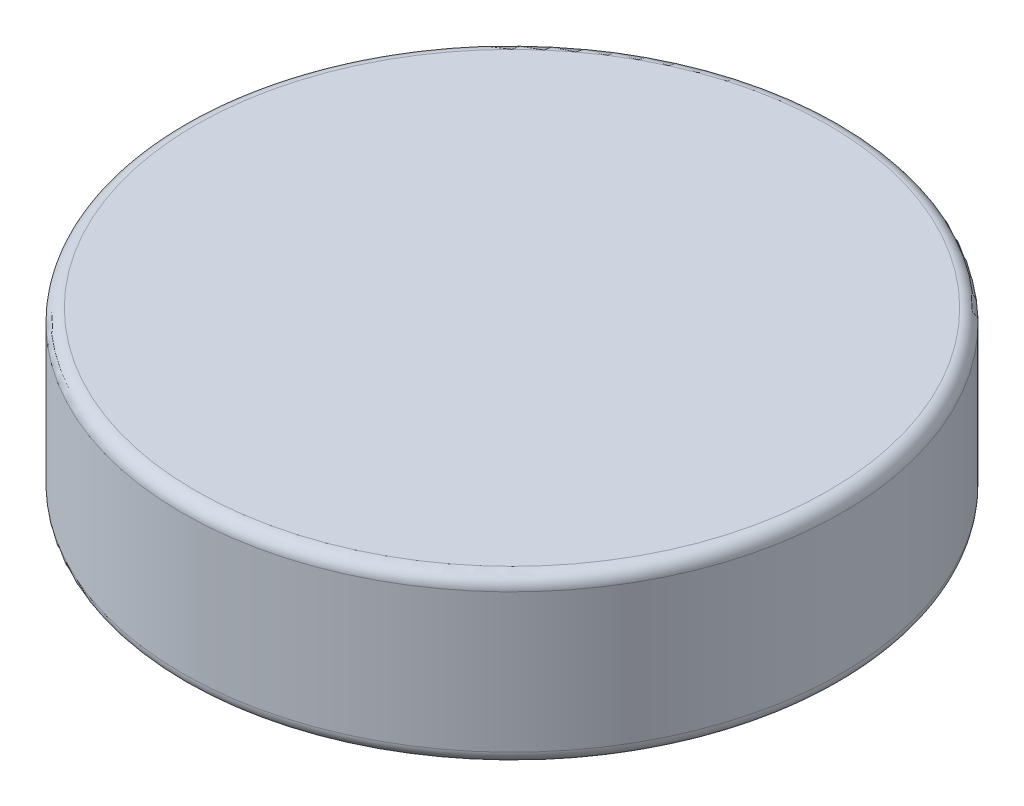
from build123d import *

# Parameters (mm, degrees)
SKETCH1_R           = 12.7
BOSS_EXTRUDE1_DEPTH = 3.175
FILLET1_R           = 0.5


with BuildPart() as part:
    # Sketch1 → Boss-Extrude1 (new body, symmetric)
    with BuildSketch(Plane(origin=(0, 0, 0), x_dir=(1, 0, 0), z_dir=(0, 1, 0))):
        Circle(SKETCH1_R)
    extrude(amount=BOSS_EXTRUDE1_DEPTH, both=True)

    # Fillet1
    fillet1_edges = [part.edges().sort_by_distance(p)[0] for p in [
        (-12.7, -3.175, 0),
        (-12.7, 3.175, 0),
    ]]
    fillet(fillet1_edges, radius=FILLET1_R)


solid = part.part
